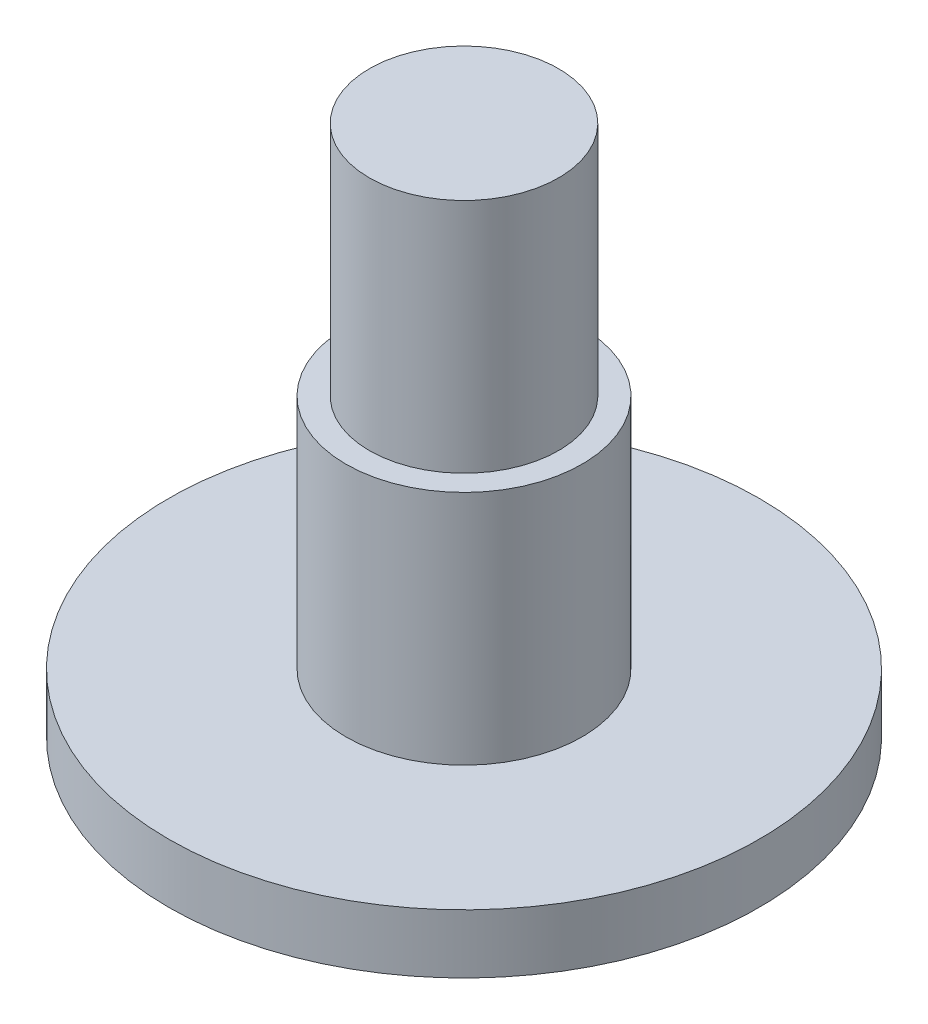
from build123d import *

# Parameters (mm, degrees)
SKETCH1_R           = 5
BOSS_EXTRUDE1_DEPTH = 1
SKETCH2_R           = 2
BOSS_EXTRUDE2_DEPTH = 4
SKETCH3_R           = 1.6025
BOSS_EXTRUDE3_DEPTH = 4


with BuildPart() as part:
    # Sketch1 → Boss-Extrude1 (new body)
    with BuildSketch(Plane(origin=(0, 0, 0), x_dir=(1, 0, 0), z_dir=(0, 1, 0))):
        Circle(SKETCH1_R)
    extrude(amount=BOSS_EXTRUDE1_DEPTH)

    # Sketch2 → Boss-Extrude2 (add)
    with BuildSketch(Plane(origin=(0, 1, 0), x_dir=(1, 0, 0), z_dir=(0, 1, 0))):
        Circle(SKETCH2_R)
    extrude(amount=BOSS_EXTRUDE2_DEPTH)

    # Sketch3 → Boss-Extrude3 (add)
    with BuildSketch(Plane(origin=(0, 5, 0), x_dir=(1, 0, 0), z_dir=(0, 1, 0))):
        Circle(SKETCH3_R)
    extrude(amount=BOSS_EXTRUDE3_DEPTH)


solid = part.part
